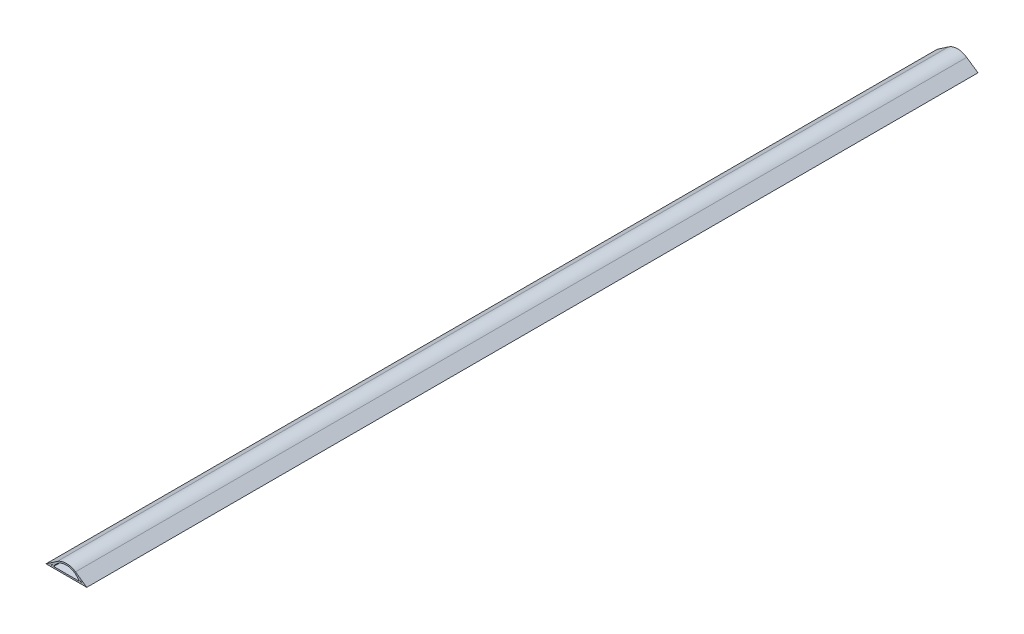
from build123d import *

# Parameters (mm, degrees)
BOSS_EXTRUDE1_DEPTH = 1498.6


with BuildPart() as part:
    # Sketch2 → Boss-Extrude1 (new body)
    with BuildSketch(Plane.XY):
        with BuildLine():
            Line((0, 0), (68.58, 0))
            Line((68.58, 0), (49.587320143, 13.03542143))
            ThreePointArc((49.587320143, 13.03542143), (34.29, 17.78), (18.992679857, 13.03542143))
            Line((18.992679857, 13.03542143), (0, 0))
        make_face()
        with BuildLine():
            Line((10.997802271, 4.46752515), (8.189387654, 2.54))
            Line((8.189387654, 2.54), (9.965035751, 2.54))
            ThreePointArc((9.965035751, 2.54), (10.461920618, 3.514209799), (10.997802271, 4.46752515))
        make_face(mode=Mode.SUBTRACT)
        with BuildLine():
            Line((57.582197729, 4.46752515), (60.390612346, 2.54))
            Line((60.390612346, 2.54), (58.614964249, 2.54))
            ThreePointArc((58.614964249, 2.54), (58.118079382, 3.514209799), (57.582197729, 4.46752515))
        make_face(mode=Mode.SUBTRACT)
        with BuildLine():
            Line((12.82308193, 2.54), (55.75691807, 2.54))
            ThreePointArc((55.75691807, 2.54), (34.29, 15.24), (12.82308193, 2.54))
        make_face(mode=Mode.SUBTRACT)
    extrude(amount=BOSS_EXTRUDE1_DEPTH)


solid = part.part
